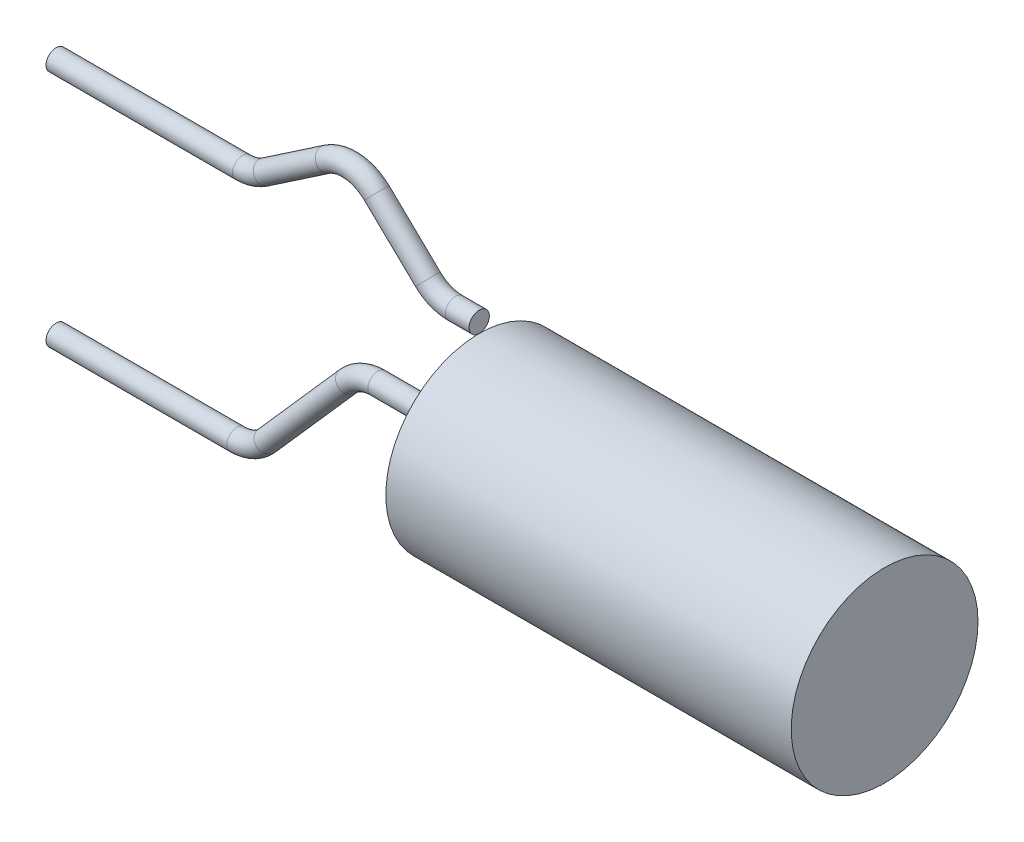
from build123d import *

# Parameters (mm, degrees)
SKETCH1_W = 10.2
SKETCH1_H = 2.35
SKETCH5_R = 0.255
SKETCH7_R = 0.255


with BuildPart() as part:
    # Sketch1 → Revolve1 (revolve)
    with BuildSketch(Plane.XY):
        with Locations((-5.1, 1.175)):
            Rectangle(SKETCH1_W, SKETCH1_H)
    revolve(axis=Axis((0, 0, 0), (-1, 0, 0)))

    # Sweep1: sweep along a path in Sketch4
    with BuildLine(Plane.XY) as sweep1_path:
        Line((-10.2, 0), (-12.74858377, 0))
        ThreePointArc((-12.74858377, 0), (-13.160021598, -0.088562172), (-13.49858377, -0.338562172))
        Line((-13.49858377, -0.338562172), (-15.547167541, -2.661437828))
        ThreePointArc((-15.547167541, -2.661437828), (-15.885729713, -2.911437828), (-16.297167541, -3))
        Line((-16.297167541, -3), (-20.845751311, -3))
    # Sketch5 → Sweep1 (sweep)
    with BuildSketch(Plane.ZY.offset(10.2)):
        Circle(SKETCH5_R)
    sweep(path=sweep1_path.line)


with BuildPart() as body_2:
    # Sweep2: sweep along a path in Sketch6
    with BuildLine(Plane.XY) as sweep2_path:
        Line((-20.845751311, 3), (-16.152872624, 3))
        ThreePointArc((-16.152872624, 3), (-15.85928544, 3.044067698), (-15.59157368, 3.172386869))
        Line((-15.59157368, 3.172386869), (-14.033231363, 4.229276693))
        ThreePointArc((-14.033231363, 4.229276693), (-13.387214162, 4.398068507), (-12.778966808, 4.1226342))
        Line((-12.778966808, 4.1226342), (-11.490305859, 2.884029361))
        ThreePointArc((-11.490305859, 2.884029361), (-11.170856888, 2.677376521), (-10.797340248, 2.605))
        Line((-10.797340248, 2.605), (-10.2, 2.605))
    # Sketch7 → Sweep2 (sweep)
    with BuildSketch(Plane.ZY.offset(10.2)):
        with Locations((0, 2.605)):
            Circle(SKETCH7_R)
    sweep(path=sweep2_path.line)


solid = Compound([part.part, body_2.part])
